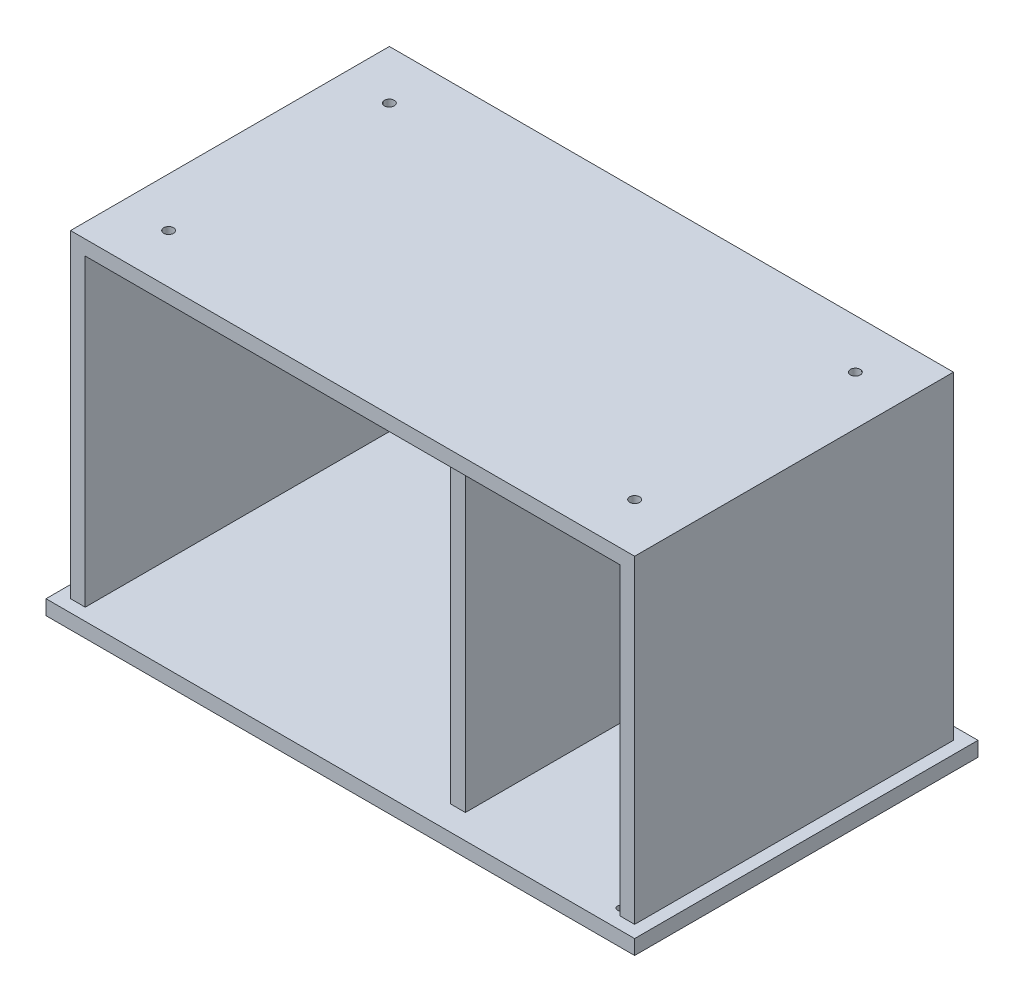
from build123d import *

# Parameters (mm, degrees)
SKETCH1_W           = 609.6
SKETCH1_H           = 355.6
BOSS_EXTRUDE1_DEPTH = 15.24
SKETCH2_R           = 15.24
CUT_EXTRUDE1_DEPTH  = 3.81
SKETCH3_W           = 584.2
SKETCH3_H           = 330.2
BOSS_EXTRUDE2_DEPTH = 330.2
SKETCH4_W           = 172.72
SKETCH4_H           = 314.96
SKETCH4_W_2         = 365.76
CUT_EXTRUDE2_DEPTH  = 330.2
SKETCH6_W           = 15.24
SKETCH6_H           = 314.96
CUT_EXTRUDE4_DEPTH  = 12.7
SKETCH8_W           = 584.2
SKETCH8_H           = 330.2
BOSS_EXTRUDE4_DEPTH = 12.7
SKETCH11_R          = 3.81
CUT_EXTRUDE5_DEPTH  = 5.08
SKETCH12_R          = 3.81
CUT_EXTRUDE6_DEPTH  = 5.08
SKETCH13_R          = 5.08
CUT_EXTRUDE7_DEPTH  = 12.7


with BuildPart() as part:
    # Sketch1 → Boss-Extrude1 (new body)
    with BuildSketch(Plane(origin=(0, 0, 0), x_dir=(1, 0, 0), z_dir=(0, 1, 0))):
        with Locations((304.8, 177.8)):
            Rectangle(SKETCH1_W, SKETCH1_H)
    extrude(amount=BOSS_EXTRUDE1_DEPTH)

    # Sketch2 → Cut-Extrude1 (cut)
    with BuildSketch(Plane(origin=(0, 0, 0), x_dir=(-1, 0, 0), z_dir=(0, -1, 0))):
        with Locations((-558.8, 50.8)):
            Circle(SKETCH2_R)
        with Locations((-558.8, 304.8)):
            Circle(SKETCH2_R)
        with Locations((-50.8, 50.8)):
            Circle(SKETCH2_R)
        with Locations((-50.8, 304.8)):
            Circle(SKETCH2_R)
    extrude(amount=-CUT_EXTRUDE1_DEPTH, mode=Mode.SUBTRACT)

    # Sketch3 → Boss-Extrude2 (add)
    with BuildSketch(Plane(origin=(0, 15.24, 0), x_dir=(1, 0, 0), z_dir=(0, 1, 0))):
        with Locations((304.8, 177.8)):
            Rectangle(SKETCH3_W, SKETCH3_H)
    extrude(amount=BOSS_EXTRUDE2_DEPTH)

    # Sketch4 → Cut-Extrude2 (cut)
    with BuildSketch(Plane.XY.offset(-12.7)):
        with Locations((495.3, 172.72)):
            Rectangle(SKETCH4_W, SKETCH4_H)
        with Locations((210.82, 172.72)):
            Rectangle(SKETCH4_W_2, SKETCH4_H)
    extrude(amount=-CUT_EXTRUDE2_DEPTH, mode=Mode.SUBTRACT)

    # Sketch6 → Cut-Extrude4 (cut)
    with BuildSketch(Plane.XY.offset(-12.7)):
        with Locations((401.32, 172.72)):
            Rectangle(SKETCH6_W, SKETCH6_H)
    extrude(amount=-CUT_EXTRUDE4_DEPTH, mode=Mode.SUBTRACT)

    # Sketch8 → Boss-Extrude4 (add)
    with BuildSketch(Plane(origin=(0, 0, -342.9), x_dir=(-1, 0, 0), z_dir=(0, 0, -1))):
        with Locations((-304.8, 180.34)):
            Rectangle(SKETCH8_W, SKETCH8_H)
    extrude(amount=-BOSS_EXTRUDE4_DEPTH)

    # Sketch11 → Cut-Extrude5 (cut)
    with BuildSketch(Plane(origin=(0, 15.24, 0), x_dir=(1, 0, 0), z_dir=(0, 1, 0))):
        with Locations((575.31, 20.32)):
            Circle(SKETCH11_R)
    extrude(amount=-CUT_EXTRUDE5_DEPTH, mode=Mode.SUBTRACT)

    # Sketch12 → Cut-Extrude6 (cut)
    with BuildSketch(Plane(origin=(0, 330.2, 0), x_dir=(-1, 0, 0), z_dir=(0, -1, 0))):
        with Locations((-575.31, 20.32)):
            Circle(SKETCH12_R)
    extrude(amount=-CUT_EXTRUDE6_DEPTH, mode=Mode.SUBTRACT)

    # Sketch13 → Cut-Extrude7 (cut)
    with BuildSketch(Plane(origin=(0, 345.44, 0), x_dir=(-1, 0, 0), z_dir=(0, 1, 0))):
        with Locations((-546.1, -63.5)):
            Circle(SKETCH13_R)
        with Locations((-63.5, -63.5)):
            Circle(SKETCH13_R)
        with Locations((-63.5, -292.1)):
            Circle(SKETCH13_R)
        with Locations((-546.1, -292.1)):
            Circle(SKETCH13_R)
    extrude(amount=-CUT_EXTRUDE7_DEPTH, mode=Mode.SUBTRACT)


solid = part.part
